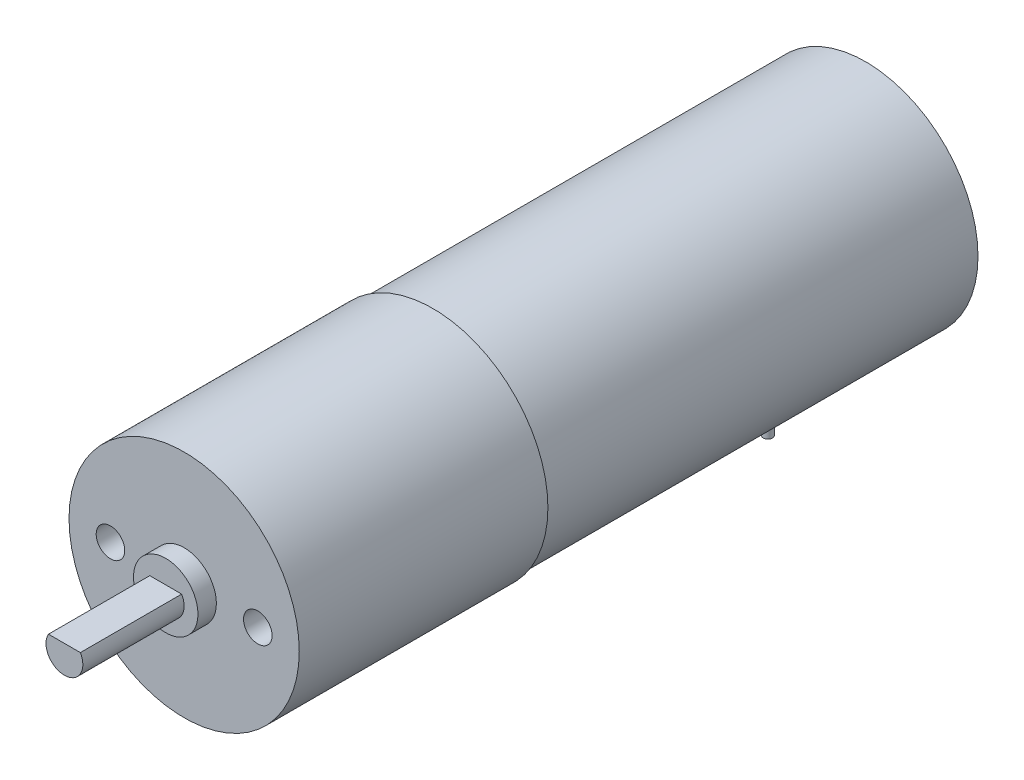
from build123d import *

# Parameters (mm, degrees)
SKETCH1_R           = 12.2
BOSS_EXTRUDE1_DEPTH = 47
SKETCH2_R           = 12.5
BOSS_EXTRUDE2_DEPTH = 27
SKETCH3_R           = 3.5
BOSS_EXTRUDE3_DEPTH = 2
BOSS_EXTRUDE4_DEPTH = 11
SKETCH6_W           = 13
SKETCH6_H           = 5
CUT_EXTRUDE1_DEPTH  = 15
SKETCH7_W           = 8
SKETCH7_H           = 3
BOSS_EXTRUDE6_DEPTH = 2.5
SKETCH8_R           = 0.5
BOSS_EXTRUDE7_DEPTH = 4
DRAFT1_ANGLE        = 5
SKETCH9_R           = 1.55
CUT_EXTRUDE2_DEPTH  = 4


with BuildPart() as part:
    # Sketch1 → Boss-Extrude1 (new body)
    with BuildSketch(Plane.XY):
        Circle(SKETCH1_R)
    extrude(amount=BOSS_EXTRUDE1_DEPTH)

    # Sketch2 → Boss-Extrude2 (add)
    with BuildSketch(Plane.XY.offset(47)):
        Circle(SKETCH2_R)
    extrude(amount=BOSS_EXTRUDE2_DEPTH)

    # Sketch3 → Boss-Extrude3 (add)
    with BuildSketch(Plane.XY.offset(74)):
        Circle(SKETCH3_R)
    extrude(amount=BOSS_EXTRUDE3_DEPTH)

    # Sketch4 → Boss-Extrude4 (add)
    with BuildSketch(Plane.XY.offset(76)):
        with BuildLine():
            Line((-1.732050808, 1), (1.732050808, 1))
            ThreePointArc((1.732050808, 1), (0, -2), (-1.732050808, 1))
        make_face()
    extrude(amount=BOSS_EXTRUDE4_DEPTH)

    # Sketch6 → Cut-Extrude1 (cut)
    with BuildSketch(Plane(origin=(0, 0, 0), x_dir=(1, 0, 0), z_dir=(0, 1, 0))):
        with Locations((0, -12.5)):
            Rectangle(SKETCH6_W, SKETCH6_H)
    extrude(amount=-CUT_EXTRUDE1_DEPTH, mode=Mode.SUBTRACT)

    # Sketch7 → Boss-Extrude6 (add)
    with BuildSketch(Plane(origin=(0, 0, 15), x_dir=(-1, 0, 0), z_dir=(0, 0, -1))):
        with Locations((-0.091140641, -9)):
            Rectangle(SKETCH7_W, SKETCH7_H)
    extrude(amount=BOSS_EXTRUDE6_DEPTH)

    # Sketch8 → Boss-Extrude7 (add)
    with BuildSketch(Plane.XZ.offset(10.5)):
        with Locations((-2.863289538, 13.75)):
            Circle(SKETCH8_R)
        with Locations((-1.663289538, 13.75)):
            Circle(SKETCH8_R)
        with Locations((-0.463289538, 13.75)):
            Circle(SKETCH8_R)
        with Locations((0.736710462, 13.75)):
            Circle(SKETCH8_R)
        with Locations((1.936710462, 13.75)):
            Circle(SKETCH8_R)
        with Locations((3.136710462, 13.75)):
            Circle(SKETCH8_R)
    extrude(amount=BOSS_EXTRUDE7_DEPTH)

    # Draft1
    draft1_faces = [part.faces().sort_by_distance(p)[0] for p in [
        (4.091140641, -9, 13.75),
        (-3.908859359, -9, 13.75),
    ]]
    draft(draft1_faces, Plane(origin=(0, 0, 12.5), x_dir=(-1, 0, 0), z_dir=(0, 0, -1)), DRAFT1_ANGLE)

    # Sketch9 → Cut-Extrude2 (cut)
    with BuildSketch(Plane.XY.offset(74)):
        with Locations((-8, 0)):
            Circle(SKETCH9_R)
        with Locations((8, 0)):
            Circle(SKETCH9_R)
    extrude(amount=-CUT_EXTRUDE2_DEPTH, mode=Mode.SUBTRACT)


solid = part.part
